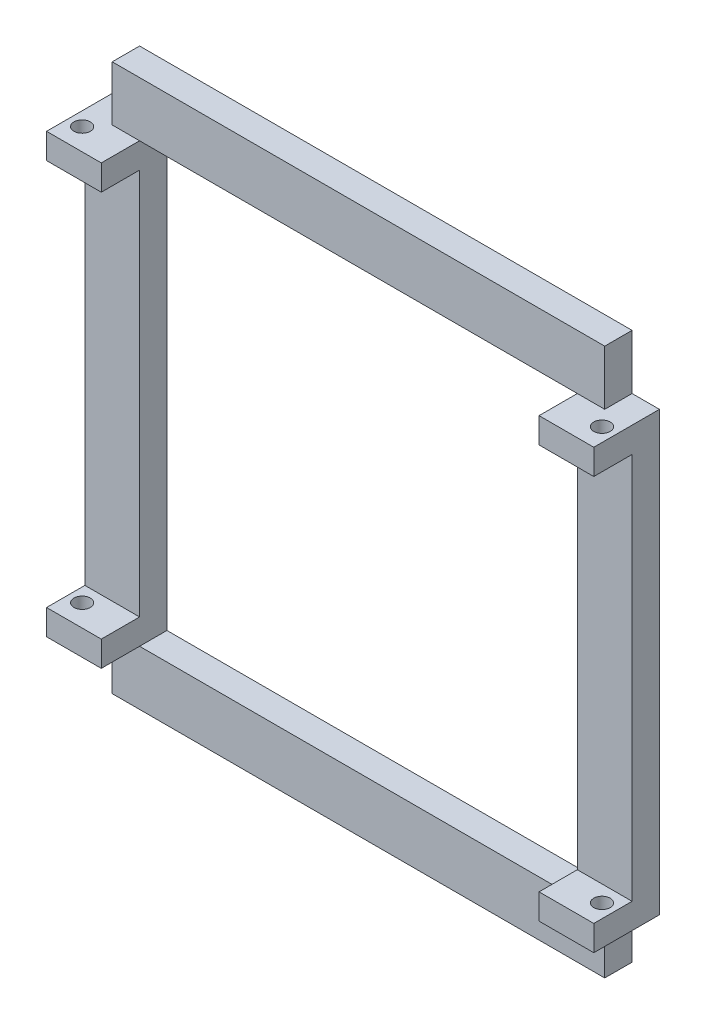
from build123d import *

# Parameters (mm, degrees)
SKETCH1_W           = 80
SKETCH1_H           = 80
BOSS_EXTRUDE1_DEPTH = 5
SKETCH2_W           = 10
SKETCH2_H           = 4.637634929
BOSS_EXTRUDE2_DEPTH = 7
SKETCH3_R           = 1.5
CUT_EXTRUDE1_DEPTH  = 91


with BuildPart() as part:
    # Sketch1 → Boss-Extrude1 (new body)
    with BuildSketch(Plane.XY):
        Polygon((-50, 40), (-45, 40), (-45, 50), (45, 50), (45, 40), (50, 40), (50, -40), (45, -40), (45, -50), (-45, -50), (-45, -40), (-50, -40), align=None)
        Rectangle(SKETCH1_W, SKETCH1_H, mode=Mode.SUBTRACT)
    extrude(amount=BOSS_EXTRUDE1_DEPTH)

    # Sketch2 → Boss-Extrude2 (add)
    with BuildSketch(Plane.XY.offset(5)):
        with Locations((45, -37.681182535)):
            Rectangle(SKETCH2_W, SKETCH2_H)
        with Locations((-45, -37.681182535)):
            Rectangle(SKETCH2_W, SKETCH2_H)
        with Locations((-45, 37.681182535)):
            Rectangle(SKETCH2_W, SKETCH2_H)
        with Locations((45, 37.681182535)):
            Rectangle(SKETCH2_W, SKETCH2_H)
    extrude(amount=BOSS_EXTRUDE2_DEPTH)

    # Sketch3 → Cut-Extrude1 (cut, through all)
    with BuildSketch(Plane.XZ.offset(40)):
        with Locations((-47.5, 8)):
            Circle(SKETCH3_R)
        with Locations((47.5, 8)):
            Circle(SKETCH3_R)
    extrude(amount=-CUT_EXTRUDE1_DEPTH, mode=Mode.SUBTRACT)


solid = part.part
